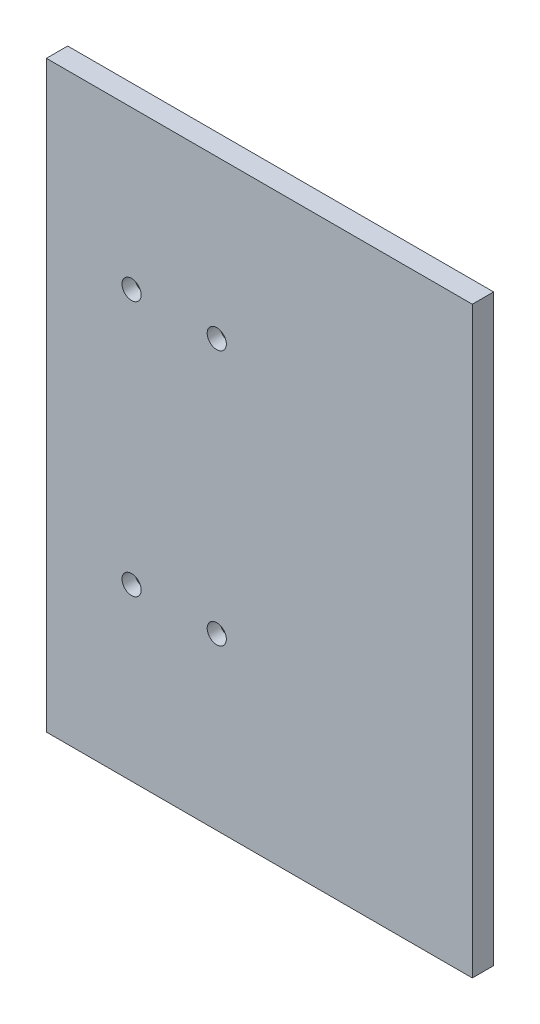
from build123d import *

# Parameters (mm, degrees)
BOSS_EXTRUDE1_DEPTH = 6.35
SKETCH3_R           = 2.8575
CUT_EXTRUDE1_DEPTH  = 3.81
SKETCH2_R           = 2.8575
CUT_EXTRUDE2_DEPTH  = 3.81


with BuildPart() as part:
    # Sketch1 → Boss-Extrude1 (new body)
    with BuildSketch(Plane.XY):
        Polygon((0, 173.99), (63.5, 173.99), (63.5, 0), (-63.5, 0), (-63.5, 173.99), align=None)
    extrude(amount=BOSS_EXTRUDE1_DEPTH)

    # Sketch3 → Cut-Extrude1 (cut)
    with BuildSketch(Plane.XY.offset(6.35)):
        with Locations((-38.1, 127)):
            Circle(SKETCH3_R)
        with Locations((-12.7, 127)):
            Circle(SKETCH3_R)
        with Locations((-38.1, 50.8)):
            Circle(SKETCH3_R)
        with Locations((-12.7, 50.8)):
            Circle(SKETCH3_R)
    extrude(amount=-CUT_EXTRUDE1_DEPTH, mode=Mode.SUBTRACT)

    # Sketch2 → Cut-Extrude2 (cut)
    with BuildSketch(Plane(origin=(0, 0, 0), x_dir=(-1, 0, 0), z_dir=(0, 0, -1))):
        with Locations((-43.064543118, 133.510265263)):
            Circle(SKETCH2_R)
        with Locations((-3.694543118, 133.510265263)):
            Circle(SKETCH2_R)
        with Locations((-43.064543118, 51.470265263)):
            Circle(SKETCH2_R)
        with Locations((-3.694543118, 51.470265263)):
            Circle(SKETCH2_R)
    extrude(amount=-CUT_EXTRUDE2_DEPTH, mode=Mode.SUBTRACT)


solid = part.part
